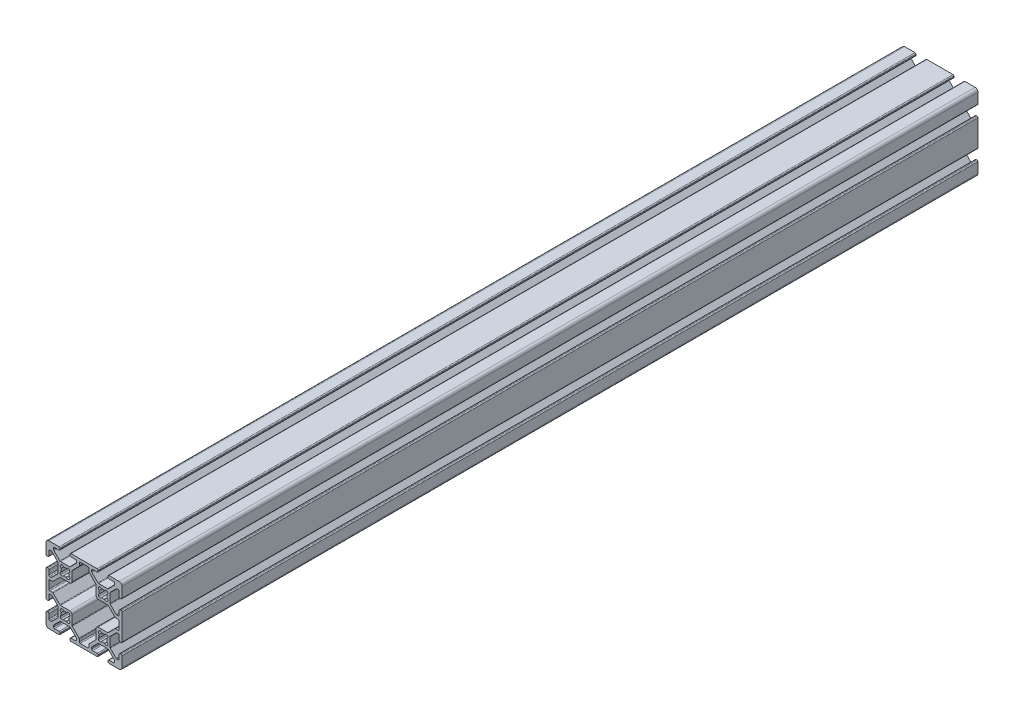
from build123d import *

# Parameters (mm, degrees)
BOSS_EXTRUDE1_DEPTH = 450


with BuildPart() as part:
    # Sketch1 → Boss-Extrude1 (new body)
    with BuildSketch(Plane(origin=(0, 0, -450), x_dir=(-1, 0, 0), z_dir=(0, 0, -1))):
        with BuildLine():
            Line((18.5, 30), (13.138, 30))
            ThreePointArc((13.138, 30), (12.778789755, 29.851210245), (12.63, 29.492))
            Line((12.63, 29.492), (12.63, 29.008))
            ThreePointArc((12.63, 29.008), (12.778789755, 28.648789755), (13.138, 28.5))
            Line((13.138, 28.5), (15.487, 28.5))
            ThreePointArc((15.487, 28.5), (15.846210245, 28.351210245), (15.995, 27.992))
            Line((15.995, 27.992), (15.995, 27.266240833))
            ThreePointArc((15.995, 27.266240833), (15.956330803, 27.07183765), (15.846210245, 26.907030588))
            Line((15.846210245, 26.907030588), (12.742969412, 23.803789755))
            ThreePointArc((12.742969412, 23.803789755), (12.57816235, 23.693669197), (12.383759167, 23.655))
            Line((12.383759167, 23.655), (7.61592049, 23.655))
            ThreePointArc((7.61592049, 23.655), (7.421517306, 23.693669197), (7.256710245, 23.803789755))
            Line((7.256710245, 23.803789755), (4.153789755, 26.906710245))
            ThreePointArc((4.153789755, 26.906710245), (4.043669197, 27.071517306), (4.005, 27.26592049))
            Line((4.005, 27.26592049), (4.005, 27.992))
            ThreePointArc((4.005, 27.992), (4.153789755, 28.351210245), (4.513, 28.5))
            Line((4.513, 28.5), (6.862, 28.5))
            ThreePointArc((6.862, 28.5), (7.221210245, 28.648789755), (7.37, 29.008))
            Line((7.37, 29.008), (7.37, 29.492))
            ThreePointArc((7.37, 29.492), (7.221210245, 29.851210245), (6.862, 30))
            Line((6.862, 30), (-6.862, 30))
            ThreePointArc((-6.862, 30), (-7.221210245, 29.851210245), (-7.37, 29.492))
            Line((-7.37, 29.492), (-7.37, 29.008))
            ThreePointArc((-7.37, 29.008), (-7.221210245, 28.648789755), (-6.862, 28.5))
            Line((-6.862, 28.5), (-4.513, 28.5))
            ThreePointArc((-4.513, 28.5), (-4.153789755, 28.351210245), (-4.005, 27.992))
            Line((-4.005, 27.992), (-4.005, 27.26592049))
            ThreePointArc((-4.005, 27.26592049), (-4.043669197, 27.071517306), (-4.153789755, 26.906710245))
            Line((-4.153789755, 26.906710245), (-7.256710245, 23.803789755))
            ThreePointArc((-7.256710245, 23.803789755), (-7.421517306, 23.693669197), (-7.61592049, 23.655))
            Line((-7.61592049, 23.655), (-12.383759167, 23.655))
            ThreePointArc((-12.383759167, 23.655), (-12.57816235, 23.693669197), (-12.742969412, 23.803789755))
            Line((-12.742969412, 23.803789755), (-15.846210245, 26.907030588))
            ThreePointArc((-15.846210245, 26.907030588), (-15.956330803, 27.07183765), (-15.995, 27.266240833))
            Line((-15.995, 27.266240833), (-15.995, 27.992))
            ThreePointArc((-15.995, 27.992), (-15.846210245, 28.351210245), (-15.487, 28.5))
            Line((-15.487, 28.5), (-13.138, 28.5))
            ThreePointArc((-13.138, 28.5), (-12.778789755, 28.648789755), (-12.63, 29.008))
            Line((-12.63, 29.008), (-12.63, 29.492))
            ThreePointArc((-12.63, 29.492), (-12.778789755, 29.851210245), (-13.138, 30))
            Line((-13.138, 30), (-18.5, 30))
            ThreePointArc((-18.5, 30), (-19.560660172, 29.560660172), (-20, 28.5))
            Line((-20, 28.5), (-20, 23.138))
            ThreePointArc((-20, 23.138), (-19.851210245, 22.778789755), (-19.492, 22.63))
            Line((-19.492, 22.63), (-19.008, 22.63))
            ThreePointArc((-19.008, 22.63), (-18.648789755, 22.778789755), (-18.5, 23.138))
            Line((-18.5, 23.138), (-18.5, 25.487))
            ThreePointArc((-18.5, 25.487), (-18.351210245, 25.846210245), (-17.992, 25.995))
            Line((-17.992, 25.995), (-17.26592049, 25.995))
            ThreePointArc((-17.26592049, 25.995), (-17.071517306, 25.956330803), (-16.906710245, 25.846210245))
            Line((-16.906710245, 25.846210245), (-13.803789755, 22.743289755))
            ThreePointArc((-13.803789755, 22.743289755), (-13.693669197, 22.578482694), (-13.655, 22.38407951))
            Line((-13.655, 22.38407951), (-13.655, 17.616240833))
            ThreePointArc((-13.655, 17.616240833), (-13.693669197, 17.42183765), (-13.803789755, 17.257030588))
            Line((-13.803789755, 17.257030588), (-16.907030588, 14.153789755))
            ThreePointArc((-16.907030588, 14.153789755), (-17.07183765, 14.043669197), (-17.266240833, 14.005))
            Line((-17.266240833, 14.005), (-17.992, 14.005))
            ThreePointArc((-17.992, 14.005), (-18.351210245, 14.153789755), (-18.5, 14.513))
            Line((-18.5, 14.513), (-18.5, 16.862))
            ThreePointArc((-18.5, 16.862), (-18.648789755, 17.221210245), (-19.008, 17.37))
            Line((-19.008, 17.37), (-19.492, 17.37))
            ThreePointArc((-19.492, 17.37), (-19.851210245, 17.221210245), (-20, 16.862))
            Line((-20, 16.862), (-20, 3.138))
            ThreePointArc((-20, 3.138), (-19.851210245, 2.778789755), (-19.492, 2.63))
            Line((-19.492, 2.63), (-19.008, 2.63))
            ThreePointArc((-19.008, 2.63), (-18.648789755, 2.778789755), (-18.5, 3.138))
            Line((-18.5, 3.138), (-18.5, 5.487))
            ThreePointArc((-18.5, 5.487), (-18.351210245, 5.846210245), (-17.992, 5.995))
            Line((-17.992, 5.995), (-17.266240833, 5.995))
            ThreePointArc((-17.266240833, 5.995), (-17.07183765, 5.956330803), (-16.907030588, 5.846210245))
            Line((-16.907030588, 5.846210245), (-13.803789755, 2.742969412))
            ThreePointArc((-13.803789755, 2.742969412), (-13.693669197, 2.57816235), (-13.655, 2.383759167))
            Line((-13.655, 2.383759167), (-13.655, -2.38407951))
            ThreePointArc((-13.655, -2.38407951), (-13.693669197, -2.578482694), (-13.803789755, -2.743289755))
            Line((-13.803789755, -2.743289755), (-16.906710245, -5.846210245))
            ThreePointArc((-16.906710245, -5.846210245), (-17.071517306, -5.956330803), (-17.26592049, -5.995))
            Line((-17.26592049, -5.995), (-17.992, -5.995))
            ThreePointArc((-17.992, -5.995), (-18.351210245, -5.846210245), (-18.5, -5.487))
            Line((-18.5, -5.487), (-18.5, -3.138))
            ThreePointArc((-18.5, -3.138), (-18.648789755, -2.778789755), (-19.008, -2.63))
            Line((-19.008, -2.63), (-19.492, -2.63))
            ThreePointArc((-19.492, -2.63), (-19.851210245, -2.778789755), (-20, -3.138))
            Line((-20, -3.138), (-20, -8.5))
            ThreePointArc((-20, -8.5), (-19.560660172, -9.560660172), (-18.5, -10))
            Line((-18.5, -10), (-13.138, -10))
            ThreePointArc((-13.138, -10), (-12.778789755, -9.851210245), (-12.63, -9.492))
            Line((-12.63, -9.492), (-12.63, -9.008))
            ThreePointArc((-12.63, -9.008), (-12.778789755, -8.648789755), (-13.138, -8.5))
            Line((-13.138, -8.5), (-15.487, -8.5))
            ThreePointArc((-15.487, -8.5), (-15.846210245, -8.351210245), (-15.995, -7.992))
            Line((-15.995, -7.992), (-15.995, -7.266240833))
            ThreePointArc((-15.995, -7.266240833), (-15.956330803, -7.07183765), (-15.846210245, -6.907030588))
            Line((-15.846210245, -6.907030588), (-12.742969412, -3.803789755))
            ThreePointArc((-12.742969412, -3.803789755), (-12.57816235, -3.693669197), (-12.383759167, -3.655))
            Line((-12.383759167, -3.655), (-7.61592049, -3.655))
            ThreePointArc((-7.61592049, -3.655), (-7.421517306, -3.693669197), (-7.256710245, -3.803789755))
            Line((-7.256710245, -3.803789755), (-4.153789755, -6.906710245))
            ThreePointArc((-4.153789755, -6.906710245), (-4.043669197, -7.071517306), (-4.005, -7.26592049))
            Line((-4.005, -7.26592049), (-4.005, -7.992))
            ThreePointArc((-4.005, -7.992), (-4.153789755, -8.351210245), (-4.513, -8.5))
            Line((-4.513, -8.5), (-6.862, -8.5))
            ThreePointArc((-6.862, -8.5), (-7.221210245, -8.648789755), (-7.37, -9.008))
            Line((-7.37, -9.008), (-7.37, -9.492))
            ThreePointArc((-7.37, -9.492), (-7.221210245, -9.851210245), (-6.862, -10))
            Line((-6.862, -10), (6.862, -10))
            ThreePointArc((6.862, -10), (7.221210245, -9.851210245), (7.37, -9.492))
            Line((7.37, -9.492), (7.37, -9.008))
            ThreePointArc((7.37, -9.008), (7.221210245, -8.648789755), (6.862, -8.5))
            Line((6.862, -8.5), (4.513, -8.5))
            ThreePointArc((4.513, -8.5), (4.153789755, -8.351210245), (4.005, -7.992))
            Line((4.005, -7.992), (4.005, -7.26592049))
            ThreePointArc((4.005, -7.26592049), (4.043669197, -7.071517306), (4.153789755, -6.906710245))
            Line((4.153789755, -6.906710245), (7.256710245, -3.803789755))
            ThreePointArc((7.256710245, -3.803789755), (7.421517306, -3.693669197), (7.61592049, -3.655))
            Line((7.61592049, -3.655), (12.383759167, -3.655))
            ThreePointArc((12.383759167, -3.655), (12.57816235, -3.693669197), (12.742969412, -3.803789755))
            Line((12.742969412, -3.803789755), (15.846210245, -6.907030588))
            ThreePointArc((15.846210245, -6.907030588), (15.956330803, -7.07183765), (15.995, -7.266240833))
            Line((15.995, -7.266240833), (15.995, -7.992))
            ThreePointArc((15.995, -7.992), (15.846210245, -8.351210245), (15.487, -8.5))
            Line((15.487, -8.5), (13.138, -8.5))
            ThreePointArc((13.138, -8.5), (12.778789755, -8.648789755), (12.63, -9.008))
            Line((12.63, -9.008), (12.63, -9.492))
            ThreePointArc((12.63, -9.492), (12.778789755, -9.851210245), (13.138, -10))
            Line((13.138, -10), (18.5, -10))
            ThreePointArc((18.5, -10), (19.560660172, -9.560660172), (20, -8.5))
            Line((20, -8.5), (20, -3.138))
            ThreePointArc((20, -3.138), (19.851210245, -2.778789755), (19.492, -2.63))
            Line((19.492, -2.63), (19.008, -2.63))
            ThreePointArc((19.008, -2.63), (18.648789755, -2.778789755), (18.5, -3.138))
            Line((18.5, -3.138), (18.5, -5.487))
            ThreePointArc((18.5, -5.487), (18.351210245, -5.846210245), (17.992, -5.995))
            Line((17.992, -5.995), (17.26592049, -5.995))
            ThreePointArc((17.26592049, -5.995), (17.071517306, -5.956330803), (16.906710245, -5.846210245))
            Line((16.906710245, -5.846210245), (13.803789755, -2.743289755))
            ThreePointArc((13.803789755, -2.743289755), (13.693669197, -2.578482694), (13.655, -2.38407951))
            Line((13.655, -2.38407951), (13.655, 2.383759167))
            ThreePointArc((13.655, 2.383759167), (13.693669197, 2.57816235), (13.803789755, 2.742969412))
            Line((13.803789755, 2.742969412), (16.907030588, 5.846210245))
            ThreePointArc((16.907030588, 5.846210245), (17.07183765, 5.956330803), (17.266240833, 5.995))
            Line((17.266240833, 5.995), (17.992, 5.995))
            ThreePointArc((17.992, 5.995), (18.351210245, 5.846210245), (18.5, 5.487))
            Line((18.5, 5.487), (18.5, 3.138))
            ThreePointArc((18.5, 3.138), (18.648789755, 2.778789755), (19.008, 2.63))
            Line((19.008, 2.63), (19.492, 2.63))
            ThreePointArc((19.492, 2.63), (19.851210245, 2.778789755), (20, 3.138))
            Line((20, 3.138), (20, 16.862))
            ThreePointArc((20, 16.862), (19.851210245, 17.221210245), (19.492, 17.37))
            Line((19.492, 17.37), (19.008, 17.37))
            ThreePointArc((19.008, 17.37), (18.648789755, 17.221210245), (18.5, 16.862))
            Line((18.5, 16.862), (18.5, 14.513))
            ThreePointArc((18.5, 14.513), (18.351210245, 14.153789755), (17.992, 14.005))
            Line((17.992, 14.005), (17.266240833, 14.005))
            ThreePointArc((17.266240833, 14.005), (17.07183765, 14.043669197), (16.907030588, 14.153789755))
            Line((16.907030588, 14.153789755), (13.803789755, 17.257030588))
            ThreePointArc((13.803789755, 17.257030588), (13.693669197, 17.42183765), (13.655, 17.616240833))
            Line((13.655, 17.616240833), (13.655, 22.38407951))
            ThreePointArc((13.655, 22.38407951), (13.693669197, 22.578482694), (13.803789755, 22.743289755))
            Line((13.803789755, 22.743289755), (16.906710245, 25.846210245))
            ThreePointArc((16.906710245, 25.846210245), (17.071517306, 25.956330803), (17.26592049, 25.995))
            Line((17.26592049, 25.995), (17.992, 25.995))
            ThreePointArc((17.992, 25.995), (18.351210245, 25.846210245), (18.5, 25.487))
            Line((18.5, 25.487), (18.5, 23.138))
            ThreePointArc((18.5, 23.138), (18.648789755, 22.778789755), (19.008, 22.63))
            Line((19.008, 22.63), (19.492, 22.63))
            ThreePointArc((19.492, 22.63), (19.851210245, 22.778789755), (20, 23.138))
            Line((20, 23.138), (20, 28.5))
            ThreePointArc((20, 28.5), (19.560660172, 29.560660172), (18.5, 30))
        make_face()
        with BuildLine():
            Line((18.5, 11.997), (18.5, 8.003))
            ThreePointArc((18.5, 8.003), (18.351210245, 7.643789755), (17.992, 7.495))
            Line((17.992, 7.495), (16.64492049, 7.495))
            ThreePointArc((16.64492049, 7.495), (16.450517306, 7.456330803), (16.285710245, 7.346210245))
            Line((16.285710245, 7.346210245), (12.743289755, 3.803789755))
            ThreePointArc((12.743289755, 3.803789755), (12.578482694, 3.693669197), (12.38407951, 3.655))
            Line((12.38407951, 3.655), (7.488, 3.655))
            ThreePointArc((7.488, 3.655), (6.679776949, 3.320223051), (6.345, 2.512))
            Line((6.345, 2.512), (6.345, -2.383759167))
            ThreePointArc((6.345, -2.383759167), (6.306330803, -2.57816235), (6.196210245, -2.742969412))
            Line((6.196210245, -2.742969412), (2.653789755, -6.285389901))
            ThreePointArc((2.653789755, -6.285389901), (2.543669197, -6.450196962), (2.505, -6.644600146))
            Line((2.505, -6.644600146), (2.505, -7.992))
            ThreePointArc((2.505, -7.992), (2.356210245, -8.351210245), (1.997, -8.5))
            Line((1.997, -8.5), (-1.997, -8.5))
            ThreePointArc((-1.997, -8.5), (-2.356210245, -8.351210245), (-2.505, -7.992))
            Line((-2.505, -7.992), (-2.505, -6.644600146))
            ThreePointArc((-2.505, -6.644600146), (-2.543669197, -6.450196962), (-2.653789755, -6.285389901))
            Line((-2.653789755, -6.285389901), (-6.196210245, -2.742969412))
            ThreePointArc((-6.196210245, -2.742969412), (-6.306330803, -2.57816235), (-6.345, -2.383759167))
            Line((-6.345, -2.383759167), (-6.345, 2.512))
            ThreePointArc((-6.345, 2.512), (-6.679776949, 3.320223051), (-7.488, 3.655))
            Line((-7.488, 3.655), (-12.38407951, 3.655))
            ThreePointArc((-12.38407951, 3.655), (-12.578482694, 3.693669197), (-12.743289755, 3.803789755))
            Line((-12.743289755, 3.803789755), (-16.285710245, 7.346210245))
            ThreePointArc((-16.285710245, 7.346210245), (-16.450517306, 7.456330803), (-16.64492049, 7.495))
            Line((-16.64492049, 7.495), (-17.992, 7.495))
            ThreePointArc((-17.992, 7.495), (-18.351210245, 7.643789755), (-18.5, 8.003))
            Line((-18.5, 8.003), (-18.5, 11.997))
            ThreePointArc((-18.5, 11.997), (-18.351210245, 12.356210245), (-17.992, 12.505))
            Line((-17.992, 12.505), (-16.64492049, 12.505))
            ThreePointArc((-16.64492049, 12.505), (-16.450517306, 12.543669197), (-16.285710245, 12.653789755))
            Line((-16.285710245, 12.653789755), (-12.743289755, 16.196210245))
            ThreePointArc((-12.743289755, 16.196210245), (-12.578482694, 16.306330803), (-12.38407951, 16.345))
            Line((-12.38407951, 16.345), (-7.488, 16.345))
            ThreePointArc((-7.488, 16.345), (-6.679776949, 16.679776949), (-6.345, 17.488))
            Line((-6.345, 17.488), (-6.345, 22.383759167))
            ThreePointArc((-6.345, 22.383759167), (-6.306330803, 22.57816235), (-6.196210245, 22.742969412))
            Line((-6.196210245, 22.742969412), (-2.653789755, 26.285389901))
            ThreePointArc((-2.653789755, 26.285389901), (-2.543669197, 26.450196962), (-2.505, 26.644600146))
            Line((-2.505, 26.644600146), (-2.505, 27.992))
            ThreePointArc((-2.505, 27.992), (-2.356210245, 28.351210245), (-1.997, 28.5))
            Line((-1.997, 28.5), (1.997, 28.5))
            ThreePointArc((1.997, 28.5), (2.356210245, 28.351210245), (2.505, 27.992))
            Line((2.505, 27.992), (2.505, 26.644600146))
            ThreePointArc((2.505, 26.644600146), (2.543669197, 26.450196962), (2.653789755, 26.285389901))
            Line((2.653789755, 26.285389901), (6.196210245, 22.742969412))
            ThreePointArc((6.196210245, 22.742969412), (6.306330803, 22.57816235), (6.345, 22.383759167))
            Line((6.345, 22.383759167), (6.345, 17.488))
            ThreePointArc((6.345, 17.488), (6.679776949, 16.679776949), (7.488, 16.345))
            Line((7.488, 16.345), (12.38407951, 16.345))
            ThreePointArc((12.38407951, 16.345), (12.578482694, 16.306330803), (12.743289755, 16.196210245))
            Line((12.743289755, 16.196210245), (16.285710245, 12.653789755))
            ThreePointArc((16.285710245, 12.653789755), (16.450517306, 12.543669197), (16.64492049, 12.505))
            Line((16.64492049, 12.505), (17.992, 12.505))
            ThreePointArc((17.992, 12.505), (18.351210245, 12.356210245), (18.5, 11.997))
        make_face(mode=Mode.SUBTRACT)
        with BuildLine():
            Line((12.124493026, 22.30449306), (12.304493036, 22.12449305))
            ThreePointArc((12.304493036, 22.12449305), (12.506016077, 21.35638568), (11.935777385, 20.80373))
            ThreePointArc((11.935777385, 20.80373), (12.095999994, 20.00000002), (11.935777391, 19.196270039))
            ThreePointArc((11.935777391, 19.196270039), (12.506016065, 18.643614345), (12.304493018, 17.875506981))
            Line((12.304493018, 17.875506981), (12.124493024, 17.695506986))
            ThreePointArc((12.124493024, 17.695506986), (11.356385664, 17.493983942), (10.803729978, 18.064222617))
            ThreePointArc((10.803729978, 18.064222617), (9.999999998, 17.904000008), (9.196270017, 18.06422261))
            ThreePointArc((9.196270017, 18.06422261), (8.643614325, 17.493983929), (7.875506957, 17.695506975))
            Line((7.875506957, 17.695506975), (7.695506957, 17.875506976))
            ThreePointArc((7.695506957, 17.875506976), (7.493983914, 18.64361434), (8.064222595, 19.196270023))
            ThreePointArc((8.064222595, 19.196270023), (7.903999986, 20.000000003), (8.064222589, 20.803729984))
            ThreePointArc((8.064222589, 20.803729984), (7.493983897, 21.356385673), (7.695506942, 22.124493047))
            Line((7.695506942, 22.124493047), (7.875506952, 22.304493057))
            ThreePointArc((7.875506952, 22.304493057), (8.643614321, 22.506016098), (9.196270002, 21.935777406))
            ThreePointArc((9.196270002, 21.935777406), (9.999999982, 22.096000015), (10.803729963, 21.935777412))
            ThreePointArc((10.803729963, 21.935777412), (11.356385652, 22.506016104), (12.124493026, 22.30449306))
        make_face(mode=Mode.SUBTRACT)
        with BuildLine():
            Line((12.304493019, -2.124493019), (12.124493021, -2.304493017))
            ThreePointArc((12.124493021, -2.304493017), (11.356385657, -2.50601606), (10.803729973, -1.935777378))
            ThreePointArc((10.803729973, -1.935777378), (10.000000001, -2.095999987), (9.196270026, -1.935777389))
            ThreePointArc((9.196270026, -1.935777389), (8.643614338, -2.506016081), (7.875506963, -2.304493037))
            Line((7.875506963, -2.304493037), (7.695506963, -2.124493037))
            ThreePointArc((7.695506963, -2.124493037), (7.493983921, -1.356385673), (8.064222602, -0.80372999))
            ThreePointArc((8.064222602, -0.80372999), (7.903999987, -4e-09), (8.064222589, 0.803729984))
            ThreePointArc((8.064222589, 0.803729984), (7.493983897, 1.356385673), (7.695506942, 2.124493047))
            Line((7.695506942, 2.124493047), (7.87550695, 2.304493055))
            ThreePointArc((7.87550695, 2.304493055), (8.643614319, 2.506016096), (9.19627, 1.935777404))
            ThreePointArc((9.19627, 1.935777404), (9.999999978, 2.096000013), (10.803729958, 1.93577741))
            ThreePointArc((10.803729958, 1.93577741), (11.356385645, 2.506016109), (12.124493023, 2.304493066))
            Line((12.124493023, 2.304493066), (12.30449304, 2.124493049))
            ThreePointArc((12.30449304, 2.124493049), (12.506016083, 1.356385671), (11.935777384, 0.803729984))
            ThreePointArc((11.935777384, 0.803729984), (12.095999987, 1.3e-08), (11.935777384, -0.803729959))
            ThreePointArc((11.935777384, -0.803729959), (12.506016065, -1.35638565), (12.304493019, -2.124493019))
        make_face(mode=Mode.SUBTRACT)
        with BuildLine():
            Line((-7.875506975, 22.304493064), (-7.695506965, 22.124493054))
            ThreePointArc((-7.695506965, 22.124493054), (-7.493983924, 21.356385684), (-8.064222616, 20.803730004))
            ThreePointArc((-8.064222616, 20.803730004), (-7.904000007, 20.000000024), (-8.06422261, 19.196270043))
            ThreePointArc((-8.06422261, 19.196270043), (-7.493983929, 18.643614351), (-7.695506975, 17.875506983))
            Line((-7.695506975, 17.875506983), (-7.875506975, 17.695506982))
            ThreePointArc((-7.875506975, 17.695506982), (-8.643614339, 17.49398394), (-9.196270022, 18.064222621))
            ThreePointArc((-9.196270022, 18.064222621), (-9.999999997, 17.904000012), (-10.803729974, 18.064222611))
            ThreePointArc((-10.803729974, 18.064222611), (-11.356385662, 17.493983919), (-12.124493037, 17.695506963))
            Line((-12.124493037, 17.695506963), (-12.304493037, 17.875506963))
            ThreePointArc((-12.304493037, 17.875506963), (-12.506016079, 18.643614327), (-11.935777398, 19.19627001))
            ThreePointArc((-11.935777398, 19.19627001), (-12.096000014, 19.999999998), (-11.935777411, 20.803729989))
            ThreePointArc((-11.935777411, 20.803729989), (-12.506016103, 21.356385677), (-12.304493059, 22.124493052))
            Line((-12.304493059, 22.124493052), (-12.124493049, 22.304493062))
            ThreePointArc((-12.124493049, 22.304493062), (-11.356385679, 22.506016103), (-10.803729999, 21.93577741))
            ThreePointArc((-10.803729999, 21.93577741), (-10.000000019, 22.096000019), (-9.196270038, 21.935777417))
            ThreePointArc((-9.196270038, 21.935777417), (-8.643614349, 22.506016108), (-7.875506975, 22.304493064))
        make_face(mode=Mode.SUBTRACT)
        with BuildLine():
            Line((-7.695506981, -2.124493019), (-7.875506979, -2.304493017))
            ThreePointArc((-7.875506979, -2.304493017), (-8.643614343, -2.50601606), (-9.196270027, -1.935777378))
            ThreePointArc((-9.196270027, -1.935777378), (-9.999999999, -2.095999987), (-10.803729974, -1.935777389))
            ThreePointArc((-10.803729974, -1.935777389), (-11.356385662, -2.506016081), (-12.124493037, -2.304493037))
            Line((-12.124493037, -2.304493037), (-12.304493037, -2.124493037))
            ThreePointArc((-12.304493037, -2.124493037), (-12.506016079, -1.356385673), (-11.935777398, -0.80372999))
            ThreePointArc((-11.935777398, -0.80372999), (-12.096000013, -4e-09), (-11.935777411, 0.803729984))
            ThreePointArc((-11.935777411, 0.803729984), (-12.506016103, 1.356385673), (-12.304493058, 2.124493047))
            Line((-12.304493058, 2.124493047), (-12.12449305, 2.304493055))
            ThreePointArc((-12.12449305, 2.304493055), (-11.356385681, 2.506016096), (-10.80373, 1.935777404))
            ThreePointArc((-10.80373, 1.935777404), (-10.000000022, 2.096000013), (-9.196270042, 1.93577741))
            ThreePointArc((-9.196270042, 1.93577741), (-8.643614353, 2.506016102), (-7.875506979, 2.304493058))
            Line((-7.875506979, 2.304493058), (-7.695506968, 2.124493047))
            ThreePointArc((-7.695506968, 2.124493047), (-7.493983924, 1.356385673), (-8.064222616, 0.803729984))
            ThreePointArc((-8.064222616, 0.803729984), (-7.904000013, 1.3e-08), (-8.064222616, -0.803729959))
            ThreePointArc((-8.064222616, -0.803729959), (-7.493983935, -1.35638565), (-7.695506981, -2.124493019))
        make_face(mode=Mode.SUBTRACT)
    extrude(amount=-BOSS_EXTRUDE1_DEPTH)


solid = part.part
